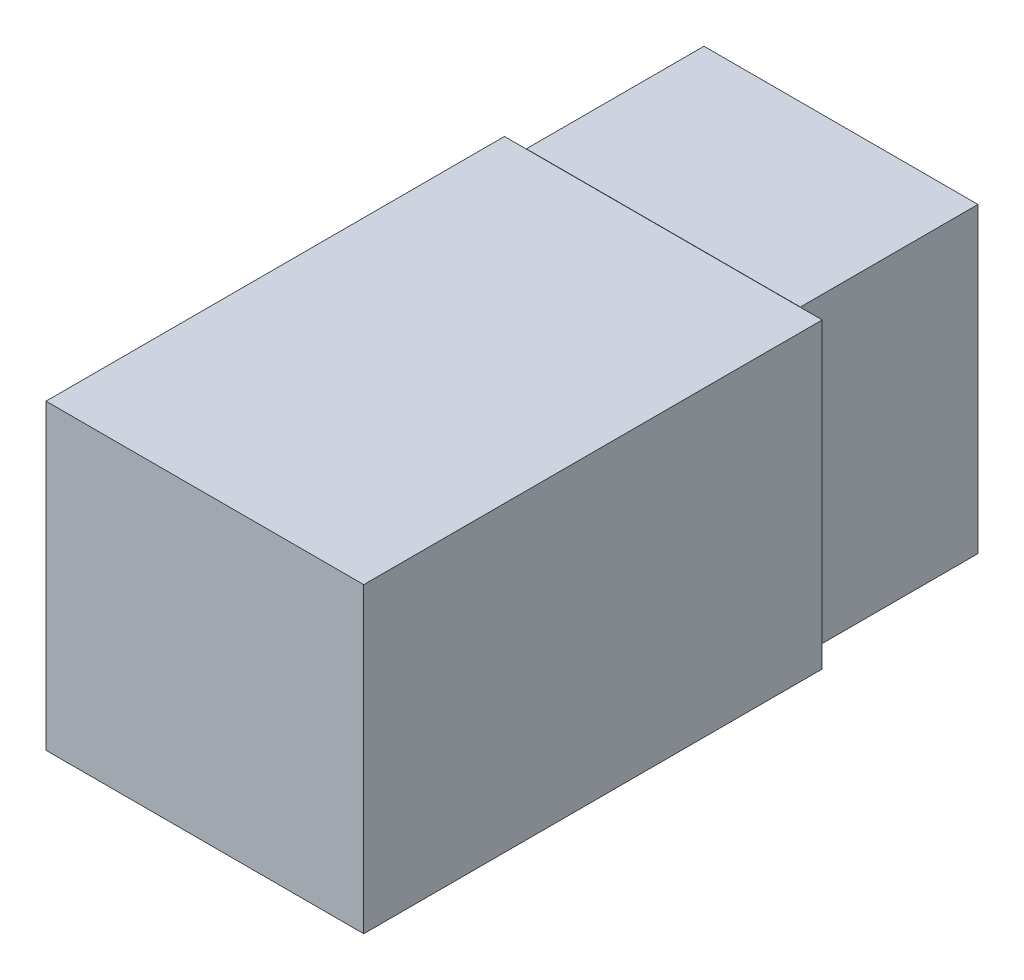
from build123d import *

# Parameters (mm, degrees)
SKETCH1_W           = 14.5
SKETCH1_H           = 16
BOSS_EXTRUDE1_DEPTH = 9.4
SKETCH4_W           = 16.813940165
SKETCH4_H           = 16
BOSS_EXTRUDE3_DEPTH = 24.26
SHELL1_T            = -1.3


with BuildPart() as part:
    # Sketch1 → Boss-Extrude1 (new body)
    with BuildSketch(Plane.XY):
        with Locations((7.25, 8)):
            Rectangle(SKETCH1_W, SKETCH1_H)
    extrude(amount=BOSS_EXTRUDE1_DEPTH)

    # Sketch4 → Boss-Extrude3 (add)
    with BuildSketch(Plane.XY.offset(9.4)):
        with Locations((7.249467392, 7.986309029)):
            Rectangle(SKETCH4_W, SKETCH4_H)
    extrude(amount=BOSS_EXTRUDE3_DEPTH)

    # Shell1
    shell1_openings = [part.faces().sort_by_distance(p)[0] for p in [
        (7.25, 8, 0),
    ]]
    offset(amount=SHELL1_T, openings=shell1_openings, kind=Kind.INTERSECTION)


solid = part.part
